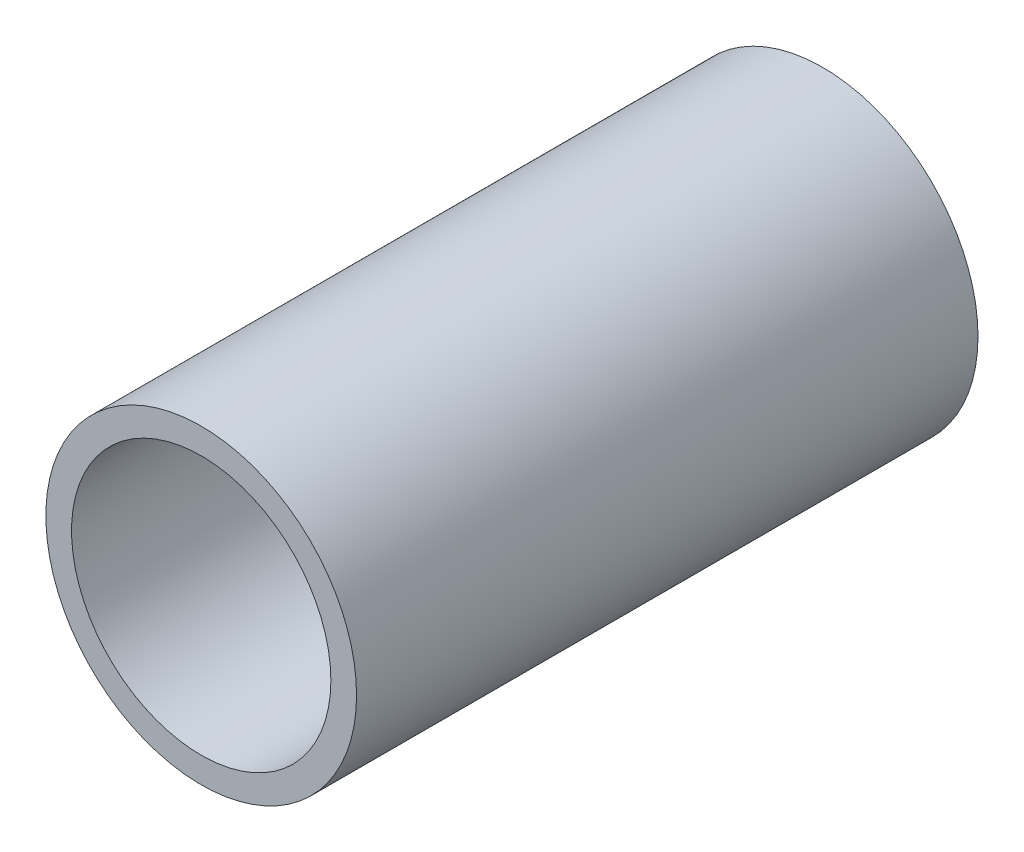
from build123d import *

# Parameters (mm, degrees)
SKETCH1_R           = 19.05
SKETCH1_R_2         = 15.9
BOSS_EXTRUDE1_DEPTH = 76.2


with BuildPart() as part:
    # Sketch1 → Boss-Extrude1 (new body)
    with BuildSketch(Plane.XY):
        Circle(SKETCH1_R)
        Circle(SKETCH1_R_2, mode=Mode.SUBTRACT)
    extrude(amount=BOSS_EXTRUDE1_DEPTH)


solid = part.part
